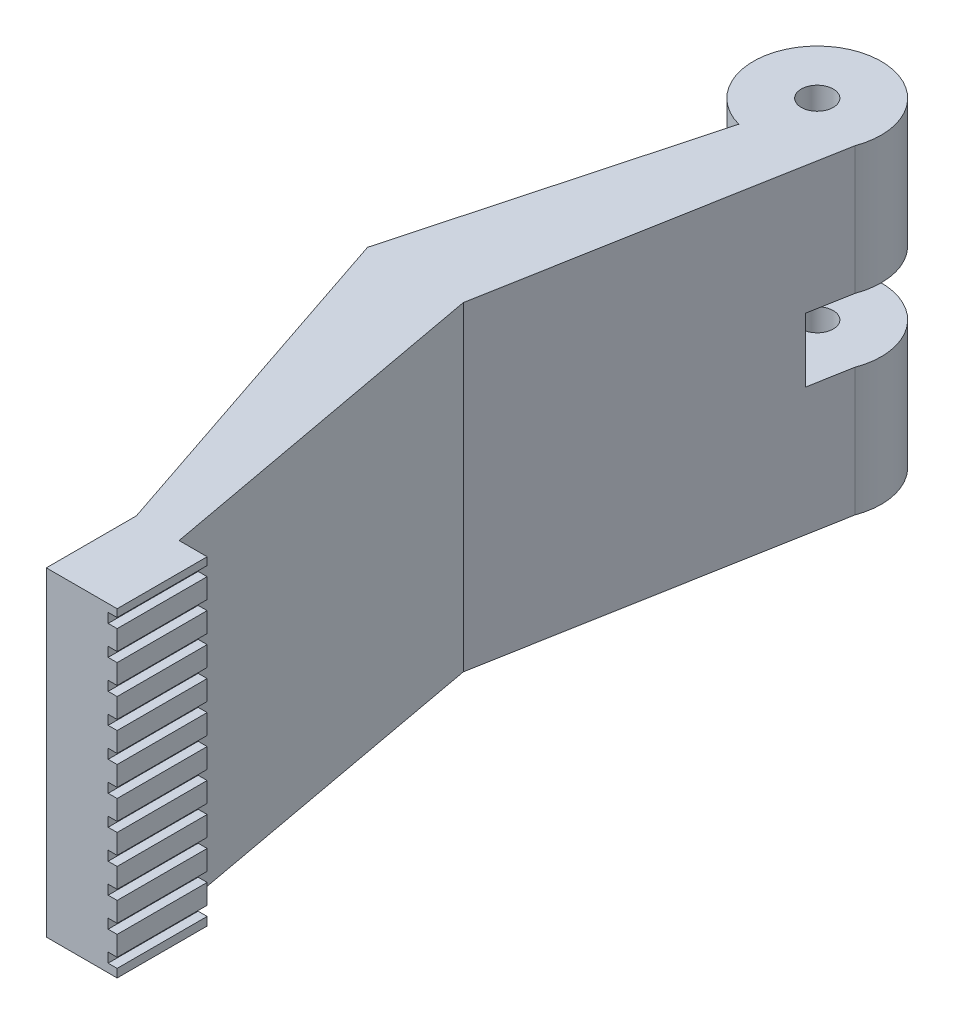
from build123d import *

# Parameters (mm, degrees)
BOSS_EXTRUDE1_DEPTH     = 50
SKETCH2_R               = 2.5
CUT_EXTRUDE1_DEPTH      = 50
SKETCH3_W               = 40
SKETCH3_H               = 10
CUT_EXTRUDE2_DEPTH      = 10
CUT_EXTRUDE2_DEPTH_BACK = 50
SKETCH4_W               = 1.407970845
SKETCH4_H               = 1.5
CUT_EXTRUDE3_DEPTH      = 50
LPATTERN1_COUNT         = 20
LPATTERN1_PITCH         = 4.6


with BuildPart() as part:
    # Sketch1 → Boss-Extrude1 (new body)
    with BuildSketch(Plane(origin=(0, 0, 0), x_dir=(1, 0, 0), z_dir=(0, 1, 0))):
        with BuildLine():
            Line((9.367667652, -3.499543222), (0.000115688, -55.342775793))
            Line((0.000115688, -55.342775793), (10, -109.773324045))
            Line((10, -109.773324045), (14.389217383, -109.773324045))
            Line((14.389217383, -109.773324045), (14.389217383, -123.847521807))
            Line((14.389217383, -123.847521807), (10, -123.847521807))
            Line((10, -123.847521807), (3.320195055, -123.847521807))
            Line((3.320195055, -123.847521807), (3.320195055, -109.773324045))
            Line((3.320195055, -109.773324045), (-14.969009399, -55.342775793))
            Line((-14.969009399, -55.342775793), (-2.61095993, -9.653128417))
            ThreePointArc((-2.61095993, -9.653128417), (-4.56945593, 8.894946459), (9.367667652, -3.499543222))
        make_face()
    extrude(amount=BOSS_EXTRUDE1_DEPTH)

    # Sketch2 → Cut-Extrude1 (cut)
    with BuildSketch(Plane(origin=(0, 50, 0), x_dir=(1, 0, 0), z_dir=(0, 1, 0))):
        Circle(SKETCH2_R)
    extrude(amount=-CUT_EXTRUDE1_DEPTH, mode=Mode.SUBTRACT)

    # Sketch3 → Cut-Extrude2 (cut, two sides)
    with BuildSketch(Plane.XY) as cut_extrude2_sk:
        with Locations((10, 25)):
            Rectangle(SKETCH3_W, SKETCH3_H)
    extrude(amount=CUT_EXTRUDE2_DEPTH, mode=Mode.SUBTRACT)
    extrude(cut_extrude2_sk.sketch, amount=-CUT_EXTRUDE2_DEPTH_BACK, mode=Mode.SUBTRACT)

    # Sketch4 → Cut-Extrude3 (cut)
    with BuildSketch(Plane.XY.offset(123.847521807)):
        with Locations((13.685231961, 48.055062802)):
            Rectangle(SKETCH4_W, SKETCH4_H)
    cut_extrude3 = extrude(amount=-CUT_EXTRUDE3_DEPTH, mode=Mode.SUBTRACT)

    # LPattern1: Cut-Extrude3 ×20
    with Locations(*[(0, -i * LPATTERN1_PITCH, 0) for i in range(1, LPATTERN1_COUNT)]):
        add(cut_extrude3, mode=Mode.SUBTRACT)


solid = part.part
